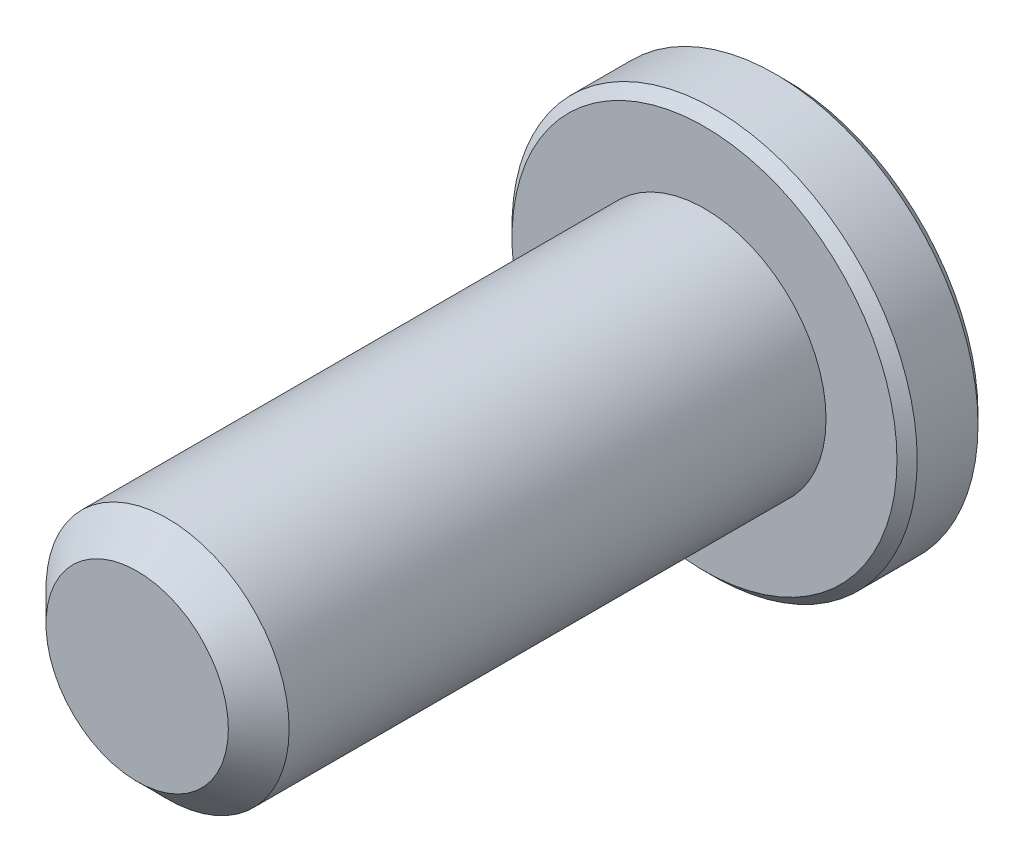
from build123d import *

# Parameters (mm, degrees)
EXTRUDE1_START     = -6
SKETCH1_R          = 3
EXTRUDE1_DEPTH     = 14
EXTRUDE2_START     = -8
SKETCH6_R          = 5
EXTRUDE2_DEPTH     = 2
CUT_EXTRUDE1_DEPTH = 1.5
SKETCH8_R          = 2.309401077
CUT_EXTRUDE2_DEPTH = 1.5
CUT_EXTRUDE2_TAPER = 45
CHAMFER1_SIZE      = 0.25
CHAMFER2_SIZE      = 0.75


with BuildPart() as part:
    # Sketch1 → Extrude1 (new body)
    with BuildSketch(Plane.XY.offset(EXTRUDE1_START)):
        Circle(SKETCH1_R)
    extrude(amount=EXTRUDE1_DEPTH)

    # Sketch6 → Extrude2 (add)
    with BuildSketch(Plane.XY.offset(EXTRUDE2_START)):
        Circle(SKETCH6_R)
    extrude(amount=EXTRUDE2_DEPTH)

    # Sketch7 → Cut-Extrude1 (cut)
    with BuildSketch(Plane.XY.offset(-8)):
        Polygon((0, 2.309401077), (-2, 1.154700538), (-2, -1.154700538), (0, -2.309401077), (2, -1.154700538), (2, 1.154700538), align=None)
    extrude(amount=CUT_EXTRUDE1_DEPTH, mode=Mode.SUBTRACT)

    # Sketch8 → Cut-Extrude2 (cut)
    with BuildSketch(Plane.XY.offset(-8)):
        Circle(SKETCH8_R)
    extrude(amount=CUT_EXTRUDE2_DEPTH, taper=CUT_EXTRUDE2_TAPER, mode=Mode.SUBTRACT)

    # Chamfer1
    chamfer1_edges = [part.edges().sort_by_distance(p)[0] for p in [
        (-5, 0, -6),
        (-5, 0, -8),
    ]]
    chamfer(chamfer1_edges, length=CHAMFER1_SIZE)

    # Chamfer2
    chamfer2_edges = [part.edges().sort_by_distance(p)[0] for p in [
        (-3, 0, 8),
    ]]
    chamfer(chamfer2_edges, length=CHAMFER2_SIZE)


solid = part.part
